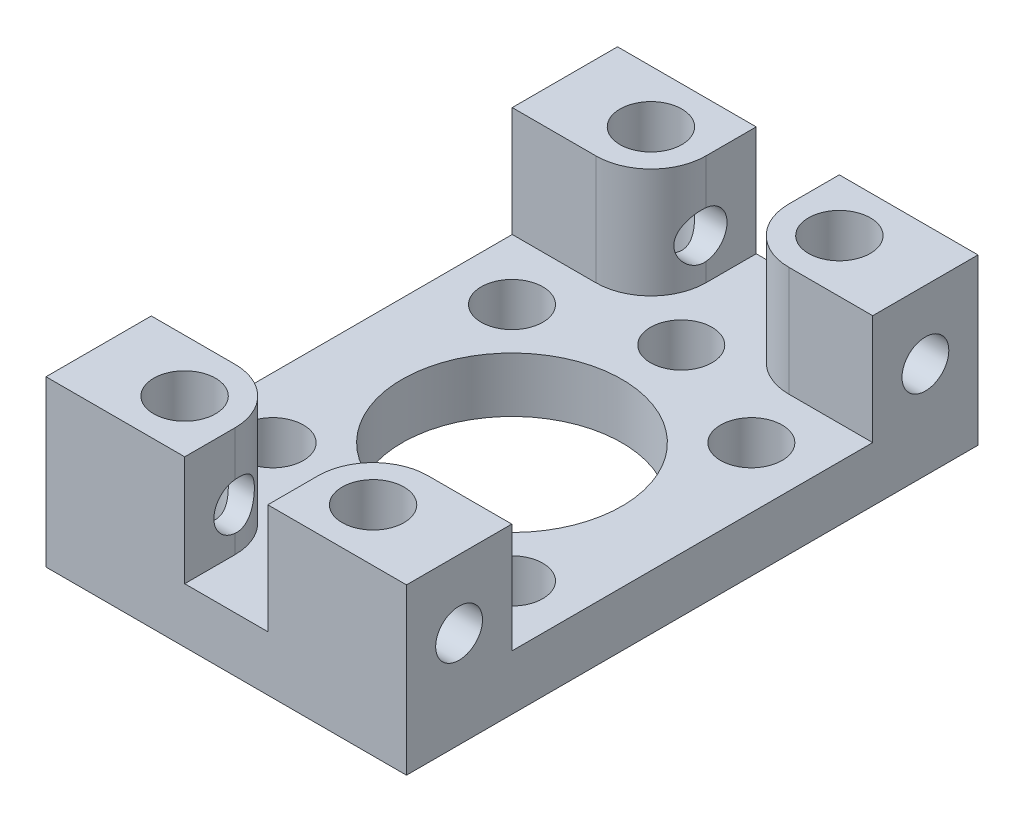
from build123d import *

# Parameters (mm, degrees)
SKETCH1_W                           = 20.828
SKETCH1_H                           = 33.02
SKETCH1_R                           = 6.35
SKETCH1_R_2                         = 1.778
BOSS_EXTRUDE1_DEPTH                 = 3.175
BOSS_EXTRUDE2_DEPTH                 = 6.35
F_9_64_0_14063_DIAMETER_HOLE1_D     = 3.572002
F_9_64_0_14063_DIAMETER_HOLE1_DEPTH = 9.525
F_6_32_TAPPED_HOLE1_D               = 2.7051
F_6_32_TAPPED_HOLE1_DEPTH           = 8.0137
F_6_32_TAPPED_HOLE1_TIP             = 0.81269403
F_6_32_TAPPED_HOLE2_D               = 2.7051
F_6_32_TAPPED_HOLE2_DEPTH           = 8.0137
F_6_32_TAPPED_HOLE2_TIP             = 0.81269403


with BuildPart() as part:
    # Sketch1 → Boss-Extrude1 (new body)
    with BuildSketch(Plane(origin=(0, 0, 0), x_dir=(1, 0, 0), z_dir=(0, 1, 0))):
        Rectangle(SKETCH1_W, SKETCH1_H)
        Circle(SKETCH1_R, mode=Mode.SUBTRACT)
        with Locations((0, 9.779)):
            Circle(SKETCH1_R_2, mode=Mode.SUBTRACT)
        with Locations((6.914797213, 6.914797213)):
            Circle(SKETCH1_R_2, mode=Mode.SUBTRACT)
        with Locations((6.914797213, -6.914797213)):
            Circle(SKETCH1_R_2, mode=Mode.SUBTRACT)
        with Locations((0, -9.779)):
            Circle(SKETCH1_R_2, mode=Mode.SUBTRACT)
        with Locations((-6.914797213, -6.914797213)):
            Circle(SKETCH1_R_2, mode=Mode.SUBTRACT)
        with Locations((-6.914797213, 6.914797213)):
            Circle(SKETCH1_R_2, mode=Mode.SUBTRACT)
    extrude(amount=BOSS_EXTRUDE1_DEPTH)

    # Sketch2 → Boss-Extrude2 (add)
    with BuildSketch(Plane(origin=(0, 3.175, 0), x_dir=(1, 0, 0), z_dir=(0, 1, 0))):
        with BuildLine():
            Line((-10.414, -16.51), (-2.4003, -16.51))
            Line((-2.4003, -16.51), (-2.4003, -13.6017))
            ThreePointArc((-2.4003, -13.6017), (-3.33023597, -11.35663597), (-5.5753, -10.4267))
            Line((-5.5753, -10.4267), (-10.414, -10.4267))
            Line((-10.414, -10.4267), (-10.414, -16.51))
        make_face()
        with BuildLine():
            Line((2.4003, -16.51), (2.4003, -13.6017))
            ThreePointArc((2.4003, -13.6017), (3.33023597, -11.35663597), (5.5753, -10.4267))
            Line((5.5753, -10.4267), (10.414, -10.4267))
            Line((10.414, -10.4267), (10.414, -16.51))
            Line((10.414, -16.51), (2.4003, -16.51))
        make_face()
        with BuildLine():
            Line((10.414, 16.51), (2.4003, 16.51))
            Line((2.4003, 16.51), (2.4003, 13.6017))
            ThreePointArc((2.4003, 13.6017), (3.33023597, 11.35663597), (5.5753, 10.4267))
            Line((5.5753, 10.4267), (10.414, 10.4267))
            Line((10.414, 10.4267), (10.414, 16.51))
        make_face()
        with BuildLine():
            Line((-2.4003, 16.51), (-2.4003, 13.6017))
            ThreePointArc((-2.4003, 13.6017), (-3.33023597, 11.35663597), (-5.5753, 10.4267))
            Line((-5.5753, 10.4267), (-10.414, 10.4267))
            Line((-10.414, 10.4267), (-10.414, 16.51))
            Line((-10.414, 16.51), (-2.4003, 16.51))
        make_face()
    extrude(amount=BOSS_EXTRUDE2_DEPTH)

    # 9/64 (0.14063) Diameter Hole1
    with Locations(Plane(origin=(0, 9.525, 0), x_dir=(-1, 0, 0), z_dir=(0, 1, 0))):
        with Locations((5.44447068, -13.470384182), (-5.44447068, -13.470384182), (-5.44447068, 13.470384182), (5.44447068, 13.470384182)):
            Hole(F_9_64_0_14063_DIAMETER_HOLE1_D / 2, depth=F_9_64_0_14063_DIAMETER_HOLE1_DEPTH)

    # #6-32 Tapped Hole1
    with Locations(Plane(origin=(10.414, 0, 0), x_dir=(0, 0, -1), z_dir=(1, 0, 0))):
        with Locations((-13.470384182, 5.588), (13.470384182, 5.588)):
            Hole(F_6_32_TAPPED_HOLE1_D / 2, depth=F_6_32_TAPPED_HOLE1_DEPTH)
            with Locations((0, 0, -(F_6_32_TAPPED_HOLE1_DEPTH + F_6_32_TAPPED_HOLE1_TIP / 2))):  # 118° drill point
                Cone(0, F_6_32_TAPPED_HOLE1_D / 2, F_6_32_TAPPED_HOLE1_TIP, mode=Mode.SUBTRACT)

    # #6-32 Tapped Hole2
    with Locations(Plane.ZY.offset(10.414)):
        with Locations((-13.470384182, 5.588), (13.470384182, 5.588)):
            Hole(F_6_32_TAPPED_HOLE2_D / 2, depth=F_6_32_TAPPED_HOLE2_DEPTH)
            with Locations((0, 0, -(F_6_32_TAPPED_HOLE2_DEPTH + F_6_32_TAPPED_HOLE2_TIP / 2))):  # 118° drill point
                Cone(0, F_6_32_TAPPED_HOLE2_D / 2, F_6_32_TAPPED_HOLE2_TIP, mode=Mode.SUBTRACT)


solid = part.part
